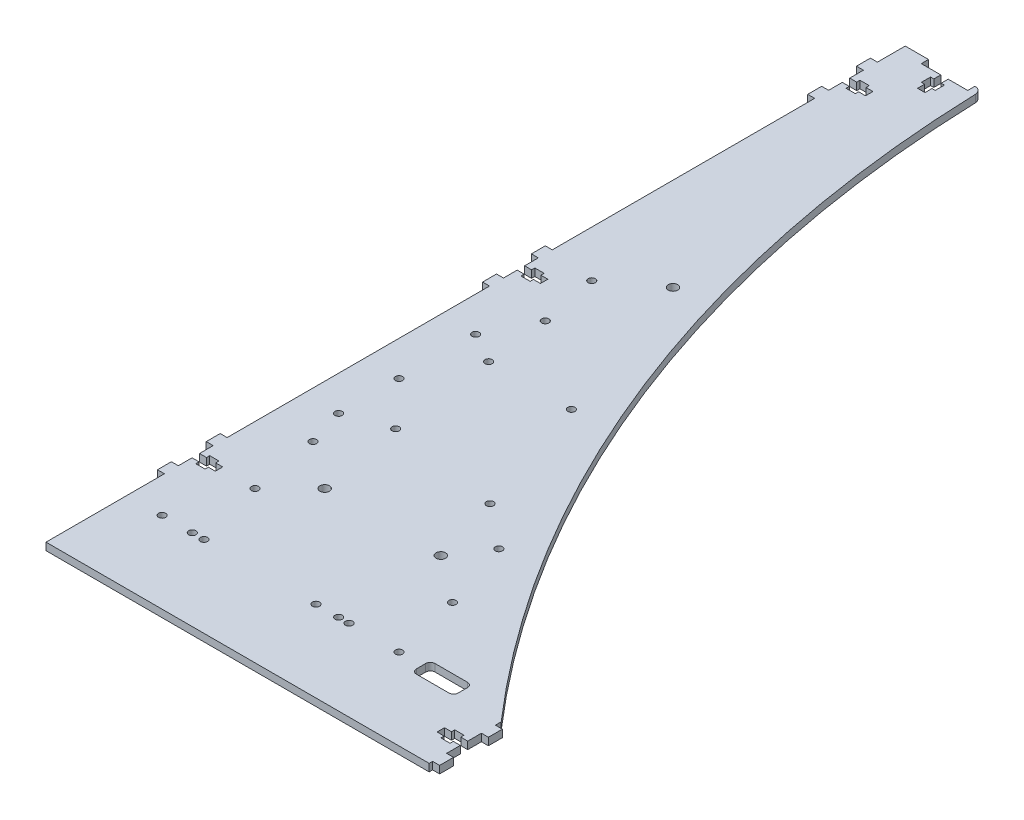
from build123d import *

# Parameters (mm, degrees)
SALIENTE_EXTRUIR1_DEPTH = 3.2
CORTAR_EXTRUIR1_DEPTH   = 3.2
REDONDEO1_R             = 3
CROQUIS3_R              = 2.05
CROQUIS3_R_2            = 1.55
CORTAR_EXTRUIR2_DEPTH   = 3.2
CROQUIS4_R              = 1.55
CORTAR_EXTRUIR3_DEPTH   = 3.2


with BuildPart() as part:
    # Croquis1 → Saliente-Extruir1 (new body)
    with BuildSketch(Plane(origin=(0, 0, 0), x_dir=(1, 0, 0), z_dir=(0, 1, 0))):
        Polygon((7, 66.1), (10, 66.1), (10, 62.9), (7, 62.9), (7, 61.5), (3, 61.5), (3, 62.9), (0, 62.9), (0, 57), (-3, 57), (-3, 51), (0, 51), (0, 0), (165, 0), (165, 1.5), (168, 1.5), (168, 7.5), (165, 7.5), (165, 13.4), (162, 13.4), (162, 12), (158, 12), (158, 13.4), (155, 13.4), (155, 16.6), (158, 16.6), (158, 18), (162, 18), (162, 16.6), (165, 16.6), (165, 22.5), (168, 22.5), (168, 28.5), (165, 28.5), (165, 370), (30, 370), (30, 366.9), (21.6, 366.9), (21.6, 363.9), (23, 363.9), (23, 359.9), (21.6, 359.9), (21.6, 356.9), (18.4, 356.9), (18.4, 359.9), (17, 359.9), (17, 363.9), (18.4, 363.9), (18.4, 366.9), (10, 366.9), (10, 370), (0, 370), (0, 358), (-3, 358), (-3, 352), (0, 352), (0, 346.1), (3, 346.1), (3, 347.5), (7, 347.5), (7, 346.1), (10, 346.1), (10, 342.9), (7, 342.9), (7, 341.5), (3, 341.5), (3, 342.9), (0, 342.9), (0, 337), (-3, 337), (-3, 331), (0, 331), (0, 218), (-3, 218), (-3, 212), (0, 212), (0, 206.1), (3, 206.1), (3, 207.5), (7, 207.5), (7, 206.1), (10, 206.1), (10, 202.9), (7, 202.9), (7, 201.5), (3, 201.5), (3, 202.9), (0, 202.9), (0, 197), (-3, 197), (-3, 191), (0, 191), (0, 78), (-3, 78), (-3, 72), (0, 72), (0, 66.1), (3, 66.1), (3, 67.5), (7, 67.5), align=None)
    extrude(amount=SALIENTE_EXTRUIR1_DEPTH)

    # Croquis2 → Cortar-Extruir1 (cut)
    with BuildSketch(Plane.XZ):
        with BuildLine():
            Line((165, -370), (33, -370))
            ThreePointArc((33, -370), (69.526447022, -189.023572292), (165, -31))
            Line((165, -31), (165, -370))
        make_face()
    extrude(amount=-CORTAR_EXTRUIR1_DEPTH, mode=Mode.SUBTRACT)

    # Redondeo1
    redondeo1_edges = [part.edges().sort_by_distance(p)[0] for p in [
        (33, 1.6, -370),
    ]]
    fillet(redondeo1_edges, radius=REDONDEO1_R)

    # Croquis3 → Cortar-Extruir2 (cut)
    with BuildSketch(Plane(origin=(0, 3.2, 0), x_dir=(1, 0, 0), z_dir=(0, 1, 0))):
        with Locations((40, 80)):
            Circle(CROQUIS3_R)
        with Locations((90, 80)):
            Circle(CROQUIS3_R)
        with Locations((40, 230)):
            Circle(CROQUIS3_R)
        with Locations((20, 95)):
            Circle(CROQUIS3_R_2)
        with Locations((20, 215)):
            Circle(CROQUIS3_R_2)
        with Locations((100, 95)):
            Circle(CROQUIS3_R_2)
        with Locations((25, 65)):
            Circle(CROQUIS3_R_2)
        with Locations((25, 190)):
            Circle(CROQUIS3_R_2)
        with Locations((110, 65)):
            Circle(CROQUIS3_R_2)
    extrude(amount=-CORTAR_EXTRUIR2_DEPTH, mode=Mode.SUBTRACT)

    # Croquis4 → Cortar-Extruir3 (cut)
    with BuildSketch(Plane.XZ):
        with Locations((15, -35)):
            Circle(CROQUIS4_R)
        with Locations((91, -35)):
            Circle(CROQUIS4_R)
        with Locations((15, -137)):
            Circle(CROQUIS4_R)
        with Locations((15, -170)):
            Circle(CROQUIS4_R)
        with Locations((33, -35)):
            Circle(CROQUIS4_R)
        with Locations((81.26, -35)):
            Circle(CROQUIS4_R)
        with Locations((33, -117.55)):
            Circle(CROQUIS4_R)
        with Locations((81.26, -109.93)):
            Circle(CROQUIS4_R)
        with Locations((28, -35)):
            Circle(CROQUIS4_R)
        with Locations((95.48, -35)):
            Circle(CROQUIS4_R)
        with Locations((28, -162.61)):
            Circle(CROQUIS4_R)
        with Locations((63.61, -162.61)):
            Circle(CROQUIS4_R)
        with Locations((117, -35)):
            Circle(CROQUIS4_R)
        with Locations((15, -111)):
            Circle(CROQUIS4_R)
        with BuildLine():
            Line((143, -30.5), (129, -30.5))
            ThreePointArc((129, -30.5), (127.585786438, -31.085786438), (127, -32.5))
            Line((127, -32.5), (127, -36.5))
            ThreePointArc((127, -36.5), (127.585786438, -37.914213562), (129, -38.5))
            Line((129, -38.5), (143, -38.5))
            ThreePointArc((143, -38.5), (144.414213562, -37.914213562), (145, -36.5))
            Line((145, -36.5), (145, -32.5))
            ThreePointArc((145, -32.5), (144.414213562, -31.085786438), (143, -30.5))
        make_face()
    extrude(amount=-CORTAR_EXTRUIR3_DEPTH, mode=Mode.SUBTRACT)


solid = part.part
